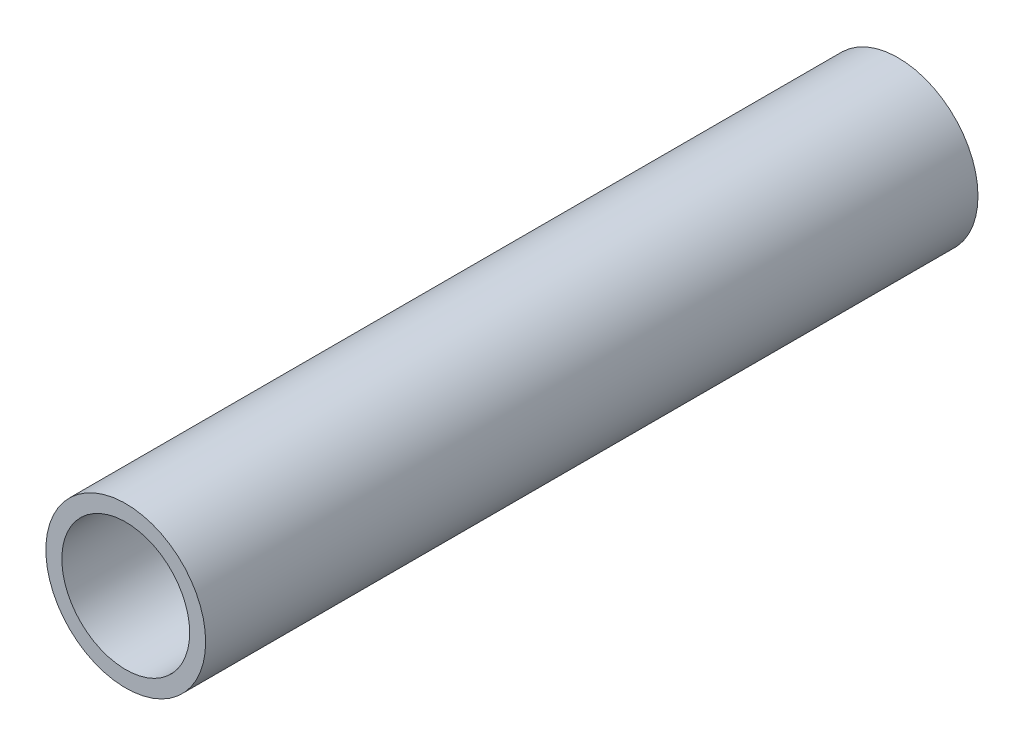
from build123d import *

# Parameters (mm, degrees)
SKETCH1_R           = 19.05
SKETCH1_R_2         = 15.24
BOSS_EXTRUDE1_DEPTH = 184.15


with BuildPart() as part:
    # Sketch1 → Boss-Extrude1 (new body)
    with BuildSketch(Plane.XY):
        Circle(SKETCH1_R)
        Circle(SKETCH1_R_2, mode=Mode.SUBTRACT)
    extrude(amount=BOSS_EXTRUDE1_DEPTH)


solid = part.part
